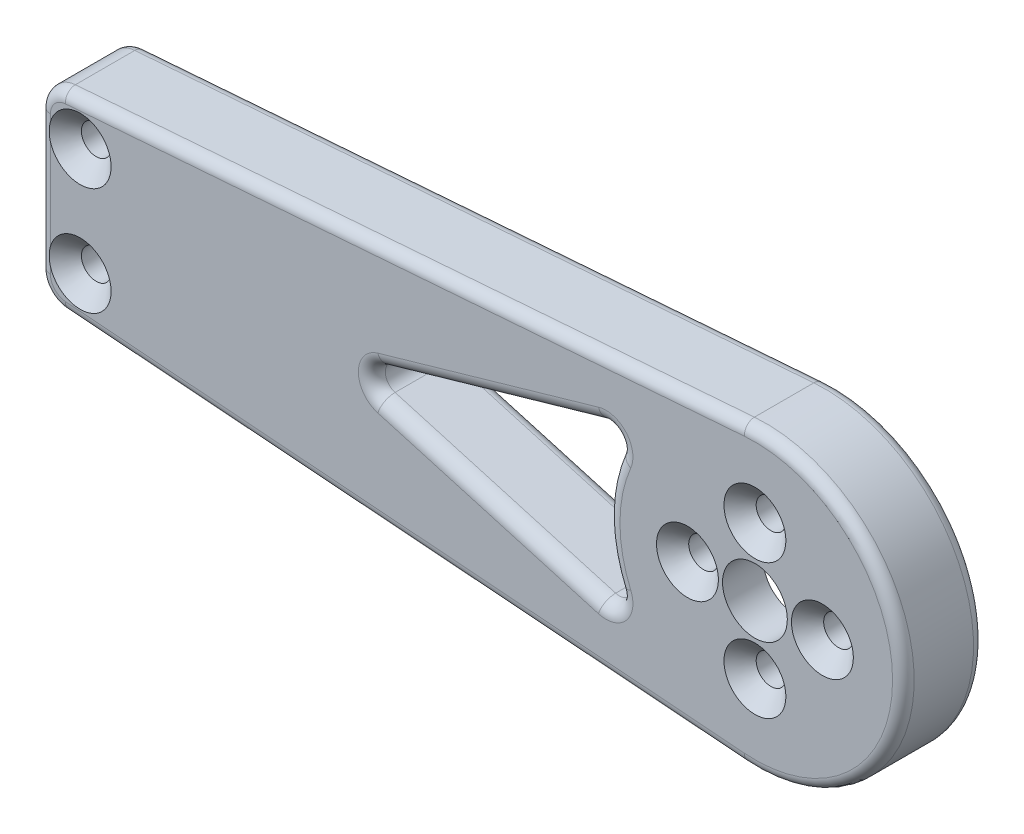
from build123d import *

# Parameters (mm, degrees)
SKETCH1_R                                            = 6
BOSS_EXTRUDE1_DEPTH                                  = 7.5
SKETCH2_R                                            = 20
CUT_EXTRUDE1_DEPTH                                   = 7.5
CUT_EXTRUDE3_DEPTH                                   = 16
CUT_EXTRUDE5_DEPTH                                   = 10
CUT_EXTRUDE6_DEPTH                                   = 10
CUT_EXTRUDE7_DEPTH                                   = 10
FILLET3_R                                            = 2.5
FILLET4_R                                            = 2
CSK_FOR_M5_HEX_SOCKET_COUNTERSUNK_HEAD_S_D           = 5.5
CSK_FOR_M5_HEX_SOCKET_COUNTERSUNK_HEAD_S_CSINK_D     = 11.47
CSK_FOR_M5_HEX_SOCKET_COUNTERSUNK_HEAD_S_CSINK_ANGLE = 90
CSK_FOR_M5_HEX_SOCKET_COUNTERSUNK_HE_2_D             = 5.5
CSK_FOR_M5_HEX_SOCKET_COUNTERSUNK_HE_2_CSINK_D       = 11.47
CSK_FOR_M5_HEX_SOCKET_COUNTERSUNK_HE_2_CSINK_ANGLE   = 90


with BuildPart() as part:
    # Sketch1 → Boss-Extrude1 (new body, symmetric)
    with BuildSketch(Plane.XY):
        with BuildLine():
            Line((-2.085935445, -27.420774484), (-127.87926099, -17.851505873))
            ThreePointArc((-127.87926099, -17.851505873), (-131.167172272, -16.264711408), (-132.5, -12.865910513))
            Line((-132.5, -12.865910513), (-132.5, 12.865910513))
            ThreePointArc((-132.5, 12.865910513), (-131.167172272, 16.264711408), (-127.87926099, 17.851505873))
            Line((-127.87926099, 17.851505873), (-2.085935445, 27.420774484))
            ThreePointArc((-2.085935445, 27.420774484), (27.5, 0), (-2.085935445, -27.420774484))
        make_face()
        Circle(SKETCH1_R, mode=Mode.SUBTRACT)
    extrude(amount=BOSS_EXTRUDE1_DEPTH, both=True)

    # Sketch2 → Cut-Extrude1 (cut)
    with BuildSketch(Plane(origin=(0, 0, -7.5), x_dir=(-1, 0, 0), z_dir=(0, 0, -1))):
        Circle(SKETCH2_R)
    extrude(amount=-CUT_EXTRUDE1_DEPTH, mode=Mode.SUBTRACT)

    # Sketch4 → Cut-Extrude3 (cut, through all)
    with BuildSketch(Plane(origin=(0, 0, -7.5), x_dir=(-1, 0, 0), z_dir=(0, 0, -1))):
        with BuildLine():
            Line((28.288155347, 14.168192599), (69.155438709, 2.40241658))
            ThreePointArc((69.155438709, 2.40241658), (70.963777971, 0), (69.155438709, -2.40241658))
            Line((69.155438709, -2.40241658), (28.288155347, -14.168192599))
            ThreePointArc((28.288155347, -14.168192599), (25.723674948, -13.42183958), (25.296786724, -10.785294684))
            ThreePointArc((25.296786724, -10.785294684), (27.5, 0), (25.296786724, 10.785294684))
            ThreePointArc((25.296786724, 10.785294684), (25.723674948, 13.42183958), (28.288155347, 14.168192599))
        make_face()
    extrude(amount=-CUT_EXTRUDE3_DEPTH, mode=Mode.SUBTRACT)

    # Sketch6 → Cut-Extrude5 (cut)
    with BuildSketch(Plane(origin=(0, 0, -7.5), x_dir=(-1, 0, 0), z_dir=(0, 0, -1))):
        with BuildLine():
            Line((58.631606678, 10.635344041), (79.355521547, 4.668885776))
            ThreePointArc((79.355521547, 4.668885776), (81.550652962, 5.073910075), (82.547182285, 7.071302356))
            Line((82.547182285, 7.071302356), (82.547182285, 11.461264354))
            ThreePointArc((82.547182285, 11.461264354), (81.880768421, 13.160664802), (80.23681278, 13.954062035))
            Line((80.23681278, 13.954062035), (59.512897911, 15.530558301))
            ThreePointArc((59.512897911, 15.530558301), (56.862822486, 13.480717442), (58.631606678, 10.635344041))
        make_face()
    cut_extrude5 = extrude(amount=-CUT_EXTRUDE5_DEPTH, mode=Mode.SUBTRACT)

    # Sketch7 → Cut-Extrude6 (cut)
    with BuildSketch(Plane(origin=(0, 0, -7.5), x_dir=(-1, 0, 0), z_dir=(0, 0, -1))):
        with BuildLine():
            Line((87.547182285, 6.799379772), (87.547182285, 10.700550813))
            ThreePointArc((87.547182285, 10.700550813), (88.347781837, 12.534136949), (90.23681278, 13.193348494))
            Line((90.23681278, 13.193348494), (104.370062578, 12.118213044))
            ThreePointArc((104.370062578, 12.118213044), (106.675825712, 9.777107925), (104.670619954, 7.173943183))
            Line((104.670619954, 7.173943183), (90.537370156, 4.347907592))
            ThreePointArc((90.537370156, 4.347907592), (88.462169616, 4.866057544), (87.547182285, 6.799379772))
        make_face()
    cut_extrude6 = extrude(amount=-CUT_EXTRUDE6_DEPTH, mode=Mode.SUBTRACT)

    # Sketch8 → Cut-Extrude7 (cut)
    with BuildSketch(Plane(origin=(0, 0, -7.5), x_dir=(-1, 0, 0), z_dir=(0, 0, -1))):
        with BuildLine():
            Line((106.553558657, -2.45147218), (114.509812129, -4.042377019))
            ThreePointArc((114.509812129, -4.042377019), (116.585012669, -3.524227067), (117.5, -1.590904838))
            Line((117.5, -1.590904838), (117.5, 1.590904838))
            ThreePointArc((117.5, 1.590904838), (116.585012669, 3.524227067), (114.509812129, 4.042377019))
            Line((114.509812129, 4.042377019), (106.553558657, 2.45147218))
            ThreePointArc((106.553558657, 2.45147218), (104.543746528, 0), (106.553558657, -2.45147218))
        make_face()
    extrude(amount=-CUT_EXTRUDE7_DEPTH, mode=Mode.SUBTRACT)

    # Mirror1: Cut-Extrude5, Cut-Extrude6 across plane
    add(cut_extrude5.mirror(Plane.ZX), mode=Mode.SUBTRACT)
    add(cut_extrude6.mirror(Plane.ZX), mode=Mode.SUBTRACT)

    # Fillet3
    fillet3_edges = [part.edges().sort_by_distance(p)[0] for p in [
        (-81.880768421, -13.160664802, 2.5),
        (-69.874855346, -14.742310168, 2.5),
        (-56.862822486, -13.480717442, 2.5),
        (-68.993564112, -7.652114908, 2.5),
        (-81.550652962, -5.073910075, 2.5),
        (-82.547182285, -9.266283355, 2.5),
        (-106.675825712, -9.777107925, 2.5),
        (-97.303437679, -12.655780769, 2.5),
        (-88.347781837, -12.534136949, 2.5),
        (-87.547182285, -8.749965293, 2.5),
        (-88.462169616, -4.866057544, 2.5),
        (-97.603995055, -5.760925387, 2.5),
        (-70.963777971, 0, 7.5),
        (-48.721797028, -8.285304589, 7.5),
        (-25.723674948, -13.42183958, 7.5),
        (-27.5, 0, 7.5),
        (-25.723674948, 13.42183958, 7.5),
        (-48.721797028, 8.285304589, 7.5),
        (-81.880768421, 13.160664802, 2.5),
        (-82.547182285, 9.266283355, 2.5),
        (-81.550652962, 5.073910075, 2.5),
        (-68.993564112, 7.652114908, 2.5),
        (-56.862822486, 13.480717442, 2.5),
        (-69.874855346, 14.742310168, 2.5),
        (-106.675825712, 9.777107925, 2.5),
        (-97.603995055, 5.760925387, 2.5),
        (-88.462169616, 4.866057544, 2.5),
        (-87.547182285, 8.749965293, 2.5),
        (-88.347781837, 12.534136949, 2.5),
        (-97.303437679, 12.655780769, 2.5),
        (-116.585012669, -3.524227067, 2.5),
        (-110.531685393, -3.246924599, 2.5),
        (-104.543746528, 0, 2.5),
        (-110.531685393, 3.246924599, 2.5),
        (-116.585012669, 3.524227067, 2.5),
        (-117.5, 0, 2.5),
    ]]
    fillet(fillet3_edges, radius=FILLET3_R)

    # Fillet4
    fillet4_edges = [part.edges().sort_by_distance(p)[0] for p in [
        (-81.880768421, -13.160664802, -7.5),
        (-69.874855346, -14.742310168, -7.5),
        (-56.862822486, -13.480717442, -7.5),
        (-68.993564112, -7.652114908, -7.5),
        (-81.550652962, -5.073910075, -7.5),
        (-82.547182285, -9.266283355, -7.5),
        (-131.167172272, 16.264711408, 7.5),
        (-106.675825712, -9.777107925, -7.5),
        (-97.303437679, -12.655780769, -7.5),
        (-88.347781837, -12.534136949, -7.5),
        (-87.547182285, -8.749965293, -7.5),
        (-88.462169616, -4.866057544, -7.5),
        (-97.603995055, -5.760925387, -7.5),
        (-132.5, 0, 7.5),
        (-131.167172272, -16.264711408, 7.5),
        (-64.982598218, -22.636140179, 7.5),
        (-70.963777971, 0, -7.5),
        (-48.721797028, 8.285304589, -7.5),
        (-25.723674948, 13.42183958, -7.5),
        (-27.5, 0, -7.5),
        (-25.723674948, -13.42183958, -7.5),
        (-48.721797028, -8.285304589, -7.5),
        (27.5, 0, 7.5),
        (-81.880768421, 13.160664802, -7.5),
        (-69.874855346, 14.742310168, -7.5),
        (-56.862822486, 13.480717442, -7.5),
        (-68.993564112, 7.652114908, -7.5),
        (-81.550652962, 5.073910075, -7.5),
        (-82.547182285, 9.266283355, -7.5),
        (-64.982598218, -22.636140179, -7.5),
        (-131.167172272, -16.264711408, -7.5),
        (-132.5, 0, -7.5),
        (-106.675825712, 9.777107925, -7.5),
        (-97.303437679, 12.655780769, -7.5),
        (-88.347781837, 12.534136949, -7.5),
        (-87.547182285, 8.749965293, -7.5),
        (-88.462169616, 4.866057544, -7.5),
        (-97.603995055, 5.760925387, -7.5),
        (-131.167172272, 16.264711408, -7.5),
        (-64.982598218, 22.636140179, -7.5),
        (27.5, 0, -7.5),
        (-64.982598218, 22.636140179, 7.5),
        (-116.585012669, -3.524227067, -7.5),
        (-117.5, 0, -7.5),
        (-116.585012669, 3.524227067, -7.5),
        (-110.531685393, 3.246924599, -7.5),
        (-104.543746528, 0, -7.5),
        (-110.531685393, -3.246924599, -7.5),
    ]]
    fillet(fillet4_edges, radius=FILLET4_R)

    # CSK for M5 Hex Socket Countersunk Head S (through all)
    with Locations(Plane.XY.offset(7.5)):
        with Locations((-12.5, 0), (0, 12.5), (12.5, 0), (0, -12.5)):
            CounterSinkHole(CSK_FOR_M5_HEX_SOCKET_COUNTERSUNK_HEAD_S_D / 2, CSK_FOR_M5_HEX_SOCKET_COUNTERSUNK_HEAD_S_CSINK_D / 2, counter_sink_angle=CSK_FOR_M5_HEX_SOCKET_COUNTERSUNK_HEAD_S_CSINK_ANGLE)

    # CSK for M5 Hex Socket Countersunk He 2 (through all)
    with Locations(Plane.XY.offset(7.5)):
        with Locations((-125, 10), (-125, -10)):
            CounterSinkHole(CSK_FOR_M5_HEX_SOCKET_COUNTERSUNK_HE_2_D / 2, CSK_FOR_M5_HEX_SOCKET_COUNTERSUNK_HE_2_CSINK_D / 2, counter_sink_angle=CSK_FOR_M5_HEX_SOCKET_COUNTERSUNK_HE_2_CSINK_ANGLE)


solid = part.part
